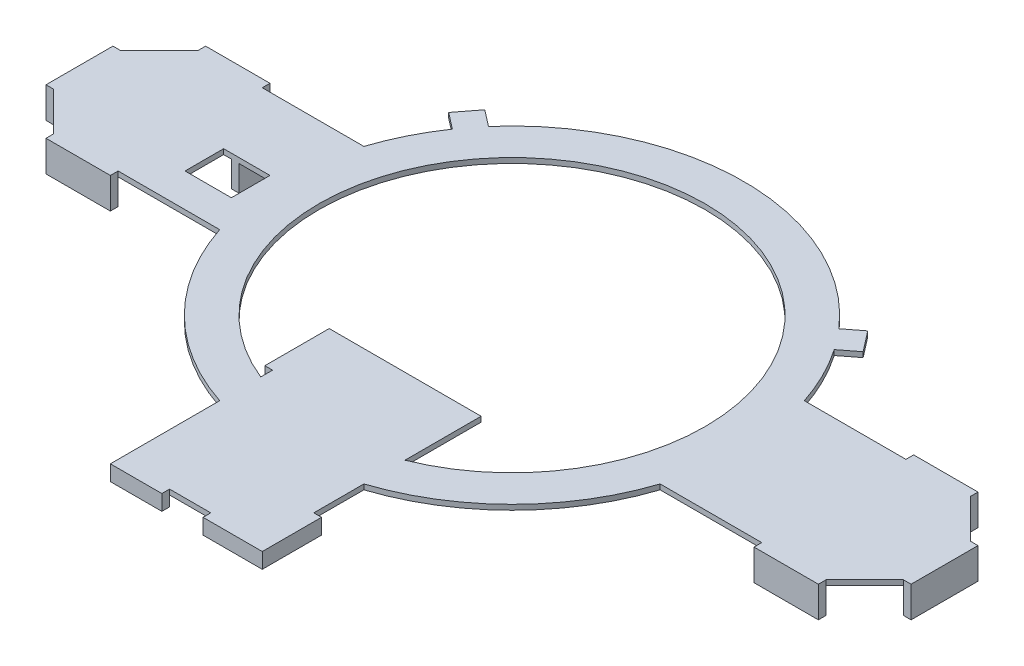
from build123d import *

# Parameters (mm, degrees)
SKETCH1_W           = 25
SKETCH1_H           = 3
SKETCH1_W_2         = 3
SKETCH1_H_2         = 9
SKETCH1_W_3         = 4
SKETCH1_H_3         = 4
SKETCH1_H_4         = 15
SKETCH1_W_4         = 20
SKETCH1_H_5         = 25
SKETCH1_H_6         = 13
BOSS_EXTRUDE3_DEPTH = 2
SKETCH2_W           = 25
SKETCH2_H           = 3
SKETCH2_W_2         = 3
SKETCH2_H_2         = 26
SKETCH2_H_3         = 13
BOSS_EXTRUDE4_DEPTH = 10
SKETCH3_W           = 3
SKETCH3_H           = 25
SKETCH3_H_2         = 20
SKETCH3_W_2         = 23
SKETCH3_H_3         = 3
SKETCH3_W_3         = 20
BOSS_EXTRUDE5_DEPTH = 4
CUT_EXTRUDE1_DEPTH  = 10


with BuildPart() as part:
    # Sketch1 → Boss-Extrude3 (new body)
    with BuildSketch(Plane(origin=(0, 0, 0), x_dir=(1, 0, 0), z_dir=(0, 1, 0))):
        with BuildLine():
            ThreePointArc((-90, 0), (-88.904443084, -14), (-85.644444444, -27.65916007))
            ThreePointArc((-85.644444444, -27.65916007), (-78.335965046, -25.45486768), (-71.894444444, -21.35857809))
            ThreePointArc((-71.894444444, -21.35857809), (-74.219550434, -10.791586229), (-75, 0))
            Line((-75, 0), (-90, 0))
        make_face()
        with BuildLine():
            ThreePointArc((-85.644444444, 27.65916007), (-88.904443084, 14), (-90, 0))
            Line((-90, 0), (-75, 0))
            ThreePointArc((-75, 0), (-74.219550434, 10.791586229), (-71.894444444, 21.35857809))
            ThreePointArc((-71.894444444, 21.35857809), (-78.335965046, 25.45486768), (-85.644444444, 27.65916007))
        make_face()
        with BuildLine():
            ThreePointArc((-90, 0), (-88.904443084, -14), (-85.644444444, -27.65916007))
            ThreePointArc((-85.644444444, -27.65916007), (-78.335965046, -25.45486768), (-71.894444444, -21.35857809))
            ThreePointArc((-71.894444444, -21.35857809), (-74.219550434, -10.791586229), (-75, 0))
            Line((-75, 0), (-90, 0))
        make_face()
        with BuildLine():
            ThreePointArc((-85.644444444, 27.65916007), (-88.904443084, 14), (-90, 0))
            Line((-90, 0), (-75, 0))
            ThreePointArc((-75, 0), (-74.219550434, 10.791586229), (-71.894444444, 21.35857809))
            ThreePointArc((-71.894444444, 21.35857809), (-78.335965046, 25.45486768), (-85.644444444, 27.65916007))
        make_face()
        with BuildLine():
            ThreePointArc((-85.644444444, -27.65916007), (-85.589201448, -27.829635202), (-85.533619121, -28))
            Line((-85.533619121, -28), (-69.577295147, -28))
            ThreePointArc((-69.577295147, -28), (-70.813772651, -24.706468849), (-71.894444444, -21.35857809))
            ThreePointArc((-71.894444444, -21.35857809), (-78.335965046, -25.45486768), (-85.644444444, -27.65916007))
        make_face()
        with BuildLine():
            ThreePointArc((-85.533619121, -28), (-63.639610307, -63.639610307), (-28, -85.533619121))
            Line((-28, -85.533619121), (-28, -69.577295147))
            ThreePointArc((-28, -69.577295147), (-53.033008589, -53.033008589), (-69.577295147, -28))
            Line((-69.577295147, -28), (-85.533619121, -28))
        make_face()
        with BuildLine():
            ThreePointArc((-85.533619121, 28), (-85.589201448, 27.829635202), (-85.644444444, 27.65916007))
            ThreePointArc((-85.644444444, 27.65916007), (-78.335965046, 25.45486768), (-71.894444444, 21.35857809))
            ThreePointArc((-71.894444444, 21.35857809), (-70.813772651, 24.706468849), (-69.577295147, 28))
            Line((-69.577295147, 28), (-85.533619121, 28))
        make_face()
        with BuildLine():
            ThreePointArc((-69.577295147, 28), (-41.982139059, 62.149014473), (0, 75))
            Line((0, 75), (0, 90))
            ThreePointArc((0, 90), (-37.402714895, 81.859861461), (-68.039579102, 58.911931521))
            Line((-68.039579102, 58.911931521), (-74.155242566, 51))
            ThreePointArc((-74.155242566, 51), (-80.668352758, 39.907604078), (-85.533619121, 28))
            Line((-85.533619121, 28), (-69.577295147, 28))
        make_face()
        with BuildLine():
            Line((-80.484787783, 55.892530771), (-74.155242566, 51))
            ThreePointArc((-74.155242566, 51), (-71.207383693, 55.040971172), (-68.039579102, 58.911931521))
            Line((-68.039579102, 58.911931521), (-74.369124319, 63.804462292))
            Line((-74.369124319, 63.804462292), (-80.484787783, 55.892530771))
        make_face()
        with BuildLine():
            Line((0, 90), (0, 75))
            ThreePointArc((0, 75), (41.982139059, 62.149014473), (69.577295147, 28))
            Line((69.577295147, 28), (85.533619121, 28))
            ThreePointArc((85.533619121, 28), (80.668352758, 39.907604078), (74.155242566, 51))
            Line((74.155242566, 51), (68.039579102, 58.911931521))
            ThreePointArc((68.039579102, 58.911931521), (37.402714895, 81.859861461), (0, 90))
        make_face()
        with BuildLine():
            ThreePointArc((68.039579102, 58.911931521), (71.207383693, 55.040971172), (74.155242566, 51))
            Line((74.155242566, 51), (80.484787783, 55.892530771))
            Line((80.484787783, 55.892530771), (74.369124319, 63.804462292))
            Line((74.369124319, 63.804462292), (68.039579102, 58.911931521))
        make_face()
        with BuildLine():
            ThreePointArc((71.894444444, 21.35857809), (78.335965046, 25.45486768), (85.644444444, 27.65916007))
            ThreePointArc((85.644444444, 27.65916007), (85.589201448, 27.829635202), (85.533619121, 28))
            Line((85.533619121, 28), (69.577295147, 28))
            ThreePointArc((69.577295147, 28), (70.813772651, 24.706468849), (71.894444444, 21.35857809))
        make_face()
        with BuildLine():
            Line((68.039579102, 58.911931521), (74.155242566, 51))
            ThreePointArc((74.155242566, 51), (71.207383693, 55.040971172), (68.039579102, 58.911931521))
        make_face()
        with BuildLine():
            ThreePointArc((-68.039579102, 58.911931521), (-71.207383693, 55.040971172), (-74.155242566, 51))
            Line((-74.155242566, 51), (-68.039579102, 58.911931521))
        make_face()
        with BuildLine():
            ThreePointArc((71.894444444, -21.35857809), (78.335965046, -25.45486768), (85.644444444, -27.65916007))
            ThreePointArc((85.644444444, -27.65916007), (88.904443084, -14), (90, 0))
            Line((90, 0), (75, 0))
            ThreePointArc((75, 0), (74.219550434, -10.791586229), (71.894444444, -21.35857809))
        make_face()
        with BuildLine():
            Line((75, 0), (90, 0))
            ThreePointArc((90, 0), (88.904443084, 14), (85.644444444, 27.65916007))
            ThreePointArc((85.644444444, 27.65916007), (78.335965046, 25.45486768), (71.894444444, 21.35857809))
            ThreePointArc((71.894444444, 21.35857809), (74.219550434, 10.791586229), (75, 0))
        make_face()
        with BuildLine():
            ThreePointArc((71.894444444, -21.35857809), (78.335965046, -25.45486768), (85.644444444, -27.65916007))
            ThreePointArc((85.644444444, -27.65916007), (88.904443084, -14), (90, 0))
            Line((90, 0), (75, 0))
            ThreePointArc((75, 0), (74.219550434, -10.791586229), (71.894444444, -21.35857809))
        make_face()
        with BuildLine():
            Line((75, 0), (90, 0))
            ThreePointArc((90, 0), (88.904443084, 14), (85.644444444, 27.65916007))
            ThreePointArc((85.644444444, 27.65916007), (78.335965046, 25.45486768), (71.894444444, 21.35857809))
            ThreePointArc((71.894444444, 21.35857809), (74.219550434, 10.791586229), (75, 0))
        make_face()
        with BuildLine():
            Line((69.577295147, -28), (85.533619121, -28))
            ThreePointArc((85.533619121, -28), (85.589201448, -27.829635202), (85.644444444, -27.65916007))
            ThreePointArc((85.644444444, -27.65916007), (78.335965046, -25.45486768), (71.894444444, -21.35857809))
            ThreePointArc((71.894444444, -21.35857809), (70.813772651, -24.706468849), (69.577295147, -28))
        make_face()
        with BuildLine():
            Line((28, -69.577295147), (28, -85.533619121))
            ThreePointArc((28, -85.533619121), (63.639610307, -63.639610307), (85.533619121, -28))
            Line((85.533619121, -28), (69.577295147, -28))
            ThreePointArc((69.577295147, -28), (53.033008589, -53.033008589), (28, -69.577295147))
        make_face()
        with BuildLine():
            ThreePointArc((-28, -85.533619121), (-14.176993318, -88.876390906), (0, -90))
            Line((0, -90), (0, -75))
            ThreePointArc((0, -75), (-14.260134361, -73.631844796), (-28, -69.577295147))
            Line((-28, -69.577295147), (-28, -85.533619121))
        make_face()
        with BuildLine():
            Line((0, -75), (0, -90))
            ThreePointArc((0, -90), (14.176993318, -88.876390906), (28, -85.533619121))
            Line((28, -85.533619121), (28, -69.577295147))
            ThreePointArc((28, -69.577295147), (14.260134361, -73.631844796), (0, -75))
        make_face()
        with BuildLine():
            Line((-165, 4), (-117.712812921, 4))
            ThreePointArc((-117.712812921, 4), (-115.733245539, 11.036307083), (-112, 17.320508076))
            Line((-112, 17.320508076), (-112, 28))
            Line((-112, 28), (-125, 28))
            Line((-125, 28), (-150, 28))
            Line((-150, 28), (-165, 28))
            Line((-165, 28), (-165, 13))
            Line((-165, 13), (-165, 4))
        make_face()
        with BuildLine():
            ThreePointArc((-112, 17.320508076), (-102.227546235, 25.189027632), (-90, 28))
            Line((-90, 28), (-112, 28))
            Line((-112, 28), (-112, 17.320508076))
        make_face()
        with Locations((-137.5, 29.5)):
            Rectangle(SKETCH1_W, SKETCH1_H)
        with BuildLine():
            Line((-165, 0), (-118, 0))
            ThreePointArc((-118, 0), (-117.928110944, 2.00514815), (-117.712812921, 4))
            Line((-117.712812921, 4), (-165, 4))
            Line((-165, 4), (-165, 0))
        make_face()
        with BuildLine():
            Line((-165, -15), (-113.643180835, -15))
            ThreePointArc((-113.643180835, -15), (-116.888743587, -7.809959559), (-118, 0))
            Line((-118, 0), (-165, 0))
            Line((-165, 0), (-165, -13))
            Line((-165, -13), (-165, -15))
        make_face()
        Polygon((-168, -13), (-165, -13), (-165, 0), (-165, 4), (-165, 13), (-168, 13), align=None)
        with BuildLine():
            Line((-118, 0), (-112, 0))
            Line((-112, 0), (-112, 4))
            Line((-112, 4), (-117.712812921, 4))
            ThreePointArc((-117.712812921, 4), (-117.928110944, 2.00514815), (-118, 0))
        make_face()
        with BuildLine():
            Line((-117.712812921, 4), (-112, 4))
            Line((-112, 4), (-112, 13))
            Line((-112, 13), (-112, 17.320508076))
            ThreePointArc((-112, 17.320508076), (-115.733245539, 11.036307083), (-117.712812921, 4))
        make_face()
        with BuildLine():
            Line((-113.643180835, -15), (-112, -15))
            Line((-112, -15), (-112, 0))
            Line((-112, 0), (-118, 0))
            ThreePointArc((-118, 0), (-116.888743587, -7.809959559), (-113.643180835, -15))
        make_face()
        with Locations((-110.5, 8.5)):
            Rectangle(SKETCH1_W_2, SKETCH1_H_2)
        with BuildLine():
            Line((-94, 4), (-90, 4))
            Line((-90, 4), (-90, 28))
            ThreePointArc((-90, 28), (-102.227546235, 25.189027632), (-112, 17.320508076))
            Line((-112, 17.320508076), (-112, 13))
            Line((-112, 13), (-109, 13))
            Line((-109, 13), (-109, 4))
            Line((-109, 4), (-94, 4))
        make_face()
        with BuildLine():
            Line((-90, -15), (-90, -28))
            ThreePointArc((-90, -28), (-87.815564372, -27.914659965), (-85.644444444, -27.65916007))
            ThreePointArc((-85.644444444, -27.65916007), (-88.904443084, -14), (-90, 0))
            Line((-90, 0), (-90, -15))
        make_face()
        with BuildLine():
            Line((-90, 4), (-90, 0))
            ThreePointArc((-90, 0), (-88.904443084, 14), (-85.644444444, 27.65916007))
            ThreePointArc((-85.644444444, 27.65916007), (-87.815564372, 27.914659965), (-90, 28))
            Line((-90, 28), (-90, 4))
        make_face()
        Polygon((-112, 0), (-94, 0), (-94, 4), (-109, 4), (-112, 4), align=None)
        with Locations((-92, 2)):
            Rectangle(SKETCH1_W_3, SKETCH1_H_3)
        with Locations((-92, -7.5)):
            Rectangle(SKETCH1_W_3, SKETCH1_H_4)
        with BuildLine():
            Line((-125, -28), (-112, -28))
            Line((-112, -28), (-112, -17.320508076))
            ThreePointArc((-112, -17.320508076), (-112.851065153, -16.181125467), (-113.643180835, -15))
            Line((-113.643180835, -15), (-165, -15))
            Line((-165, -15), (-165, -28))
            Line((-165, -28), (-150, -28))
            Line((-150, -28), (-125, -28))
        make_face()
        with Locations((-137.5, -29.5)):
            Rectangle(SKETCH1_W, SKETCH1_H)
        with BuildLine():
            ThreePointArc((-113.643180835, -15), (-112.851065153, -16.181125467), (-112, -17.320508076))
            Line((-112, -17.320508076), (-112, -15))
            Line((-112, -15), (-113.643180835, -15))
        make_face()
        with BuildLine():
            ThreePointArc((-112, -17.320508076), (-102.227546235, -25.189027632), (-90, -28))
            Line((-90, -28), (-90, -15))
            Line((-90, -15), (-94, -15))
            Line((-94, -15), (-112, -15))
            Line((-112, -15), (-112, -17.320508076))
        make_face()
        with BuildLine():
            Line((-112, -28), (-90, -28))
            ThreePointArc((-90, -28), (-102.227546235, -25.189027632), (-112, -17.320508076))
            Line((-112, -17.320508076), (-112, -28))
        make_face()
        with BuildLine():
            Line((-90, -15), (-90, -28))
            ThreePointArc((-90, -28), (-87.815564372, -27.914659965), (-85.644444444, -27.65916007))
            ThreePointArc((-85.644444444, -27.65916007), (-88.904443084, -14), (-90, 0))
            Line((-90, 0), (-90, -15))
        make_face()
        with BuildLine():
            Line((-90, 4), (-90, 0))
            ThreePointArc((-90, 0), (-88.904443084, 14), (-85.644444444, 27.65916007))
            ThreePointArc((-85.644444444, 27.65916007), (-87.815564372, 27.914659965), (-90, 28))
            Line((-90, 28), (-90, 4))
        make_face()
        with BuildLine():
            Line((-90, -28), (-85.533619121, -28))
            ThreePointArc((-85.533619121, -28), (-85.589201448, -27.829635202), (-85.644444444, -27.65916007))
            ThreePointArc((-85.644444444, -27.65916007), (-87.815564372, -27.914659965), (-90, -28))
        make_face()
        with BuildLine():
            ThreePointArc((28, -85.533619121), (14.176993318, -88.876390906), (0, -90))
            ThreePointArc((0, -90), (-14.176993318, -88.876390906), (-28, -85.533619121))
            Line((-28, -85.533619121), (-28, -125))
            Line((-28, -125), (-8, -125))
            Line((-8, -125), (8, -125))
            Line((8, -125), (28, -125))
            Line((28, -125), (28, -105))
            Line((28, -105), (28, -85.533619121))
        make_face()
        with Locations((-18, -126.5)):
            Rectangle(SKETCH1_W_4, SKETCH1_H)
        with Locations((18, -126.5)):
            Rectangle(SKETCH1_W_4, SKETCH1_H)
        Polygon((31, -105), (28, -105), (28, -125), (28, -128), (31, -128), align=None)
        with BuildLine():
            ThreePointArc((-28, -69.577295147), (-14.260134361, -73.631844796), (0, -75))
            Line((0, -75), (0, -40))
            Line((0, -40), (-28, -40))
            Line((-28, -40), (-28, -65))
            Line((-28, -65), (-28, -69.577295147))
        make_face()
        with BuildLine():
            Line((0, -40), (0, -75))
            ThreePointArc((0, -75), (14.260134361, -73.631844796), (28, -69.577295147))
            Line((28, -69.577295147), (28, -40))
            Line((28, -40), (0, -40))
        make_face()
        with Locations((-29.5, -52.5)):
            Rectangle(SKETCH1_W_2, SKETCH1_H_5)
        with BuildLine():
            ThreePointArc((85.644444444, -27.65916007), (87.815564372, -27.914659965), (90, -28))
            Line((90, -28), (90, 0))
            ThreePointArc((90, 0), (88.904443084, -14), (85.644444444, -27.65916007))
        make_face()
        with BuildLine():
            ThreePointArc((85.644444444, 27.65916007), (88.904443084, 14), (90, 0))
            Line((90, 0), (90, 28))
            ThreePointArc((90, 28), (87.815564372, 27.914659965), (85.644444444, 27.65916007))
        make_face()
        with BuildLine():
            ThreePointArc((85.644444444, -27.65916007), (87.815564372, -27.914659965), (90, -28))
            Line((90, -28), (90, 0))
            ThreePointArc((90, 0), (88.904443084, -14), (85.644444444, -27.65916007))
        make_face()
        with BuildLine():
            ThreePointArc((85.644444444, 27.65916007), (88.904443084, 14), (90, 0))
            Line((90, 0), (90, 28))
            ThreePointArc((90, 28), (87.815564372, 27.914659965), (85.644444444, 27.65916007))
        make_face()
        with BuildLine():
            ThreePointArc((85.644444444, 27.65916007), (87.815564372, 27.914659965), (90, 28))
            Line((90, 28), (85.533619121, 28))
            ThreePointArc((85.533619121, 28), (85.589201448, 27.829635202), (85.644444444, 27.65916007))
        make_face()
        with BuildLine():
            Line((90, 28), (90, 0))
            Line((90, 0), (107, 0))
            Line((107, 0), (107, 13))
            Line((107, 13), (110, 13))
            Line((110, 13), (110, 0))
            Line((110, 0), (118, 0))
            ThreePointArc((118, 0), (109.798989873, 19.798989873), (90, 28))
        make_face()
        with BuildLine():
            ThreePointArc((90, 28), (109.798989873, 19.798989873), (118, 0))
            Line((118, 0), (165, 0))
            Line((165, 0), (165, 13))
            Line((165, 13), (165, 28))
            Line((165, 28), (150, 28))
            Line((150, 28), (125, 28))
            Line((125, 28), (90, 28))
        make_face()
        with BuildLine():
            ThreePointArc((85.644444444, -27.65916007), (85.589201448, -27.829635202), (85.533619121, -28))
            Line((85.533619121, -28), (90, -28))
            ThreePointArc((90, -28), (87.815564372, -27.914659965), (85.644444444, -27.65916007))
        make_face()
        with BuildLine():
            Line((90, 0), (90, -28))
            ThreePointArc((90, -28), (109.798989873, -19.798989873), (118, 0))
            Line((118, 0), (110, 0))
            Line((110, 0), (110, -13))
            Line((110, -13), (107, -13))
            Line((107, -13), (107, 0))
            Line((107, 0), (90, 0))
        make_face()
        with BuildLine():
            ThreePointArc((118, 0), (109.798989873, -19.798989873), (90, -28))
            Line((90, -28), (125, -28))
            Line((125, -28), (150, -28))
            Line((150, -28), (165, -28))
            Line((165, -28), (165, -13))
            Line((165, -13), (165, 0))
            Line((165, 0), (118, 0))
        make_face()
        Polygon((165, 13), (165, 0), (165, -13), (168, -13), (168, 13), align=None)
        with Locations((137.5, -29.5)):
            Rectangle(SKETCH1_W, SKETCH1_H)
        with Locations((137.5, 29.5)):
            Rectangle(SKETCH1_W, SKETCH1_H)
        with Locations((108.5, 6.5)):
            Rectangle(SKETCH1_W_2, SKETCH1_H_6)
        with Locations((108.5, -6.5)):
            Rectangle(SKETCH1_W_2, SKETCH1_H_6)
        with BuildLine():
            ThreePointArc((-90, 28), (-87.815564372, 27.914659965), (-85.644444444, 27.65916007))
            ThreePointArc((-85.644444444, 27.65916007), (-85.589201448, 27.829635202), (-85.533619121, 28))
            Line((-85.533619121, 28), (-90, 28))
        make_face()
    extrude(amount=-BOSS_EXTRUDE3_DEPTH)

    # Sketch2 → Boss-Extrude4 (add)
    with BuildSketch(Plane.XZ.offset(2)):
        with Locations((137.5, 29.5)):
            Rectangle(SKETCH2_W, SKETCH2_H)
        with Locations((107.5, 0)):
            Rectangle(SKETCH2_W_2, SKETCH2_H_2)
        with Locations((166.5, 0)):
            Rectangle(SKETCH2_W_2, SKETCH2_H_2)
        with Locations((137.5, -29.5)):
            Rectangle(SKETCH2_W, SKETCH2_H)
        with Locations((-166.5, 0)):
            Rectangle(SKETCH2_W_2, SKETCH2_H_2)
        with Locations((-137.5, -29.5)):
            Rectangle(SKETCH2_W, SKETCH2_H)
        with Locations((-107.5, -6.5)):
            Rectangle(SKETCH2_W_2, SKETCH2_H_3)
        with Locations((-137.5, 29.5)):
            Rectangle(SKETCH2_W, SKETCH2_H)
    extrude(amount=BOSS_EXTRUDE4_DEPTH)

    # Sketch3 → Boss-Extrude5 (add)
    with BuildSketch(Plane(origin=(0, -2, 0), x_dir=(-1, 0, 0), z_dir=(0, -1, 0))):
        with Locations((29.5, -52.5)):
            Rectangle(SKETCH3_W, SKETCH3_H)
        with Locations((-29.5, -115)):
            Rectangle(SKETCH3_W, SKETCH3_H_2)
        with Locations((-19.5, -126.5)):
            Rectangle(SKETCH3_W_2, SKETCH3_H_3)
        with Locations((18, -126.5)):
            Rectangle(SKETCH3_W_3, SKETCH3_H_3)
    extrude(amount=BOSS_EXTRUDE5_DEPTH)

    # Sketch4 → Cut-Extrude1 (cut)
    with BuildSketch(Plane.XZ.offset(2)):
        Polygon((-150, 28), (-165, 28), (-165, 13), align=None)
        Polygon((-165, -13), (-165, -28), (-150, -28), align=None)
        Polygon((165, 28), (165, 13), (150, 28), align=None)
        Polygon((165, -28), (150, -28), (165, -13), align=None)
    extrude(amount=-CUT_EXTRUDE1_DEPTH, mode=Mode.SUBTRACT)


solid = part.part
